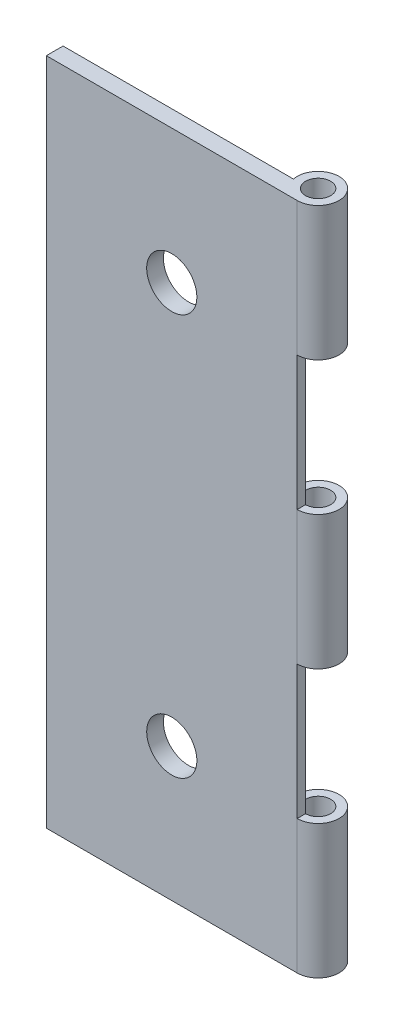
from build123d import *

# Parameters (mm, degrees)
SKETCH1_W           = 15
SKETCH1_H           = 40
SKETCH1_R           = 1.5
BOSS_EXTRUDE2_DEPTH = 1
SKETCH2_R           = 1.25
BOSS_EXTRUDE3_DEPTH = 8
SKETCH3_R           = 0.75
CUT_EXTRUDE1_DEPTH  = 40
LPATTERN1_COUNT     = 3
LPATTERN1_PITCH     = 16
SKETCH4_R           = 0.75
CUT_EXTRUDE2_DEPTH  = 40


with BuildPart() as part:
    # Sketch1 → Boss-Extrude2 (new body)
    with BuildSketch(Plane.XY):
        Rectangle(SKETCH1_W, SKETCH1_H)
        with Locations((0, 12)):
            Circle(SKETCH1_R, mode=Mode.SUBTRACT)
        with Locations((0, -12)):
            Circle(SKETCH1_R, mode=Mode.SUBTRACT)
    extrude(amount=BOSS_EXTRUDE2_DEPTH)

    # Sketch2 → Boss-Extrude3 (add)
    with BuildSketch(Plane(origin=(0, 20, 0), x_dir=(1, 0, 0), z_dir=(0, 1, 0))):
        with Locations((7.5, 0.25)):
            Circle(SKETCH2_R)
    boss_extrude3 = extrude(amount=-BOSS_EXTRUDE3_DEPTH)

    # Sketch3 → Cut-Extrude1 (cut)
    with BuildSketch(Plane(origin=(0, 20, 0), x_dir=(1, 0, 0), z_dir=(0, 1, 0))):
        with Locations((7.5, 0.25)):
            Circle(SKETCH3_R)
    extrude(amount=-CUT_EXTRUDE1_DEPTH, mode=Mode.SUBTRACT)

    # LPattern1: Boss-Extrude3 ×3
    with Locations(*[(0, -i * LPATTERN1_PITCH, 0) for i in range(1, LPATTERN1_COUNT)]):
        add(boss_extrude3)

    # Sketch4 → Cut-Extrude2 (cut)
    with BuildSketch(Plane(origin=(0, 20, 0), x_dir=(1, 0, 0), z_dir=(0, 1, 0))):
        with Locations((7.5, 0.25)):
            Circle(SKETCH4_R)
    extrude(amount=-CUT_EXTRUDE2_DEPTH, mode=Mode.SUBTRACT)


solid = part.part
